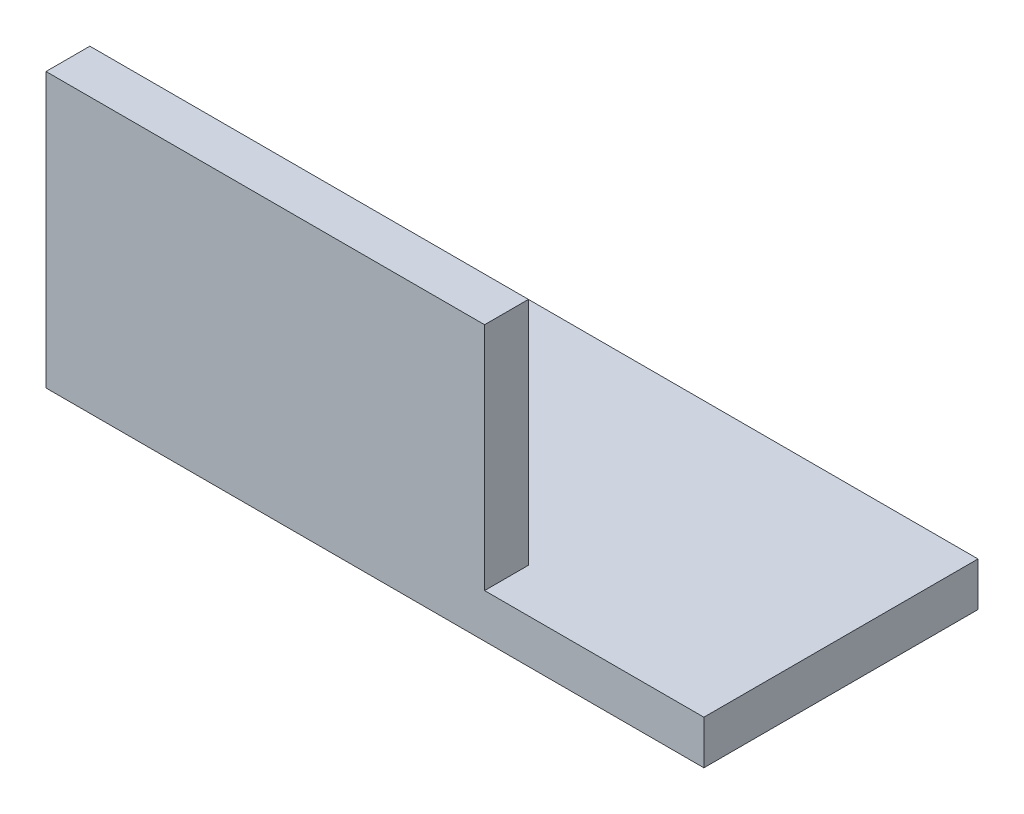
from build123d import *

# Parameters (mm, degrees)
EXTRUDE_1_DEPTH     = 60
SKETCH_2_W          = 20
SKETCH_2_H          = 21
CUT_EXTRUDE_1_DEPTH = 26


with BuildPart() as part:
    # Эскиз1 → Вытянуть-Тонкостенный1 (new body)
    with BuildSketch(Plane(origin=(0, 0, 0), x_dir=(0, 0, -1), z_dir=(1, 0, 0))):
        Polygon((0, 25), (0, 0), (25, 0), (25, 4), (4, 4), (4, 25), align=None)
    extrude(amount=EXTRUDE_1_DEPTH)

    # Эскиз2 → Вырез-Вытянуть1 (cut, through all)
    with BuildSketch(Plane.XY):
        with Locations((50, 14.5)):
            Rectangle(SKETCH_2_W, SKETCH_2_H)
    extrude(amount=-CUT_EXTRUDE_1_DEPTH, mode=Mode.SUBTRACT)


solid = part.part
